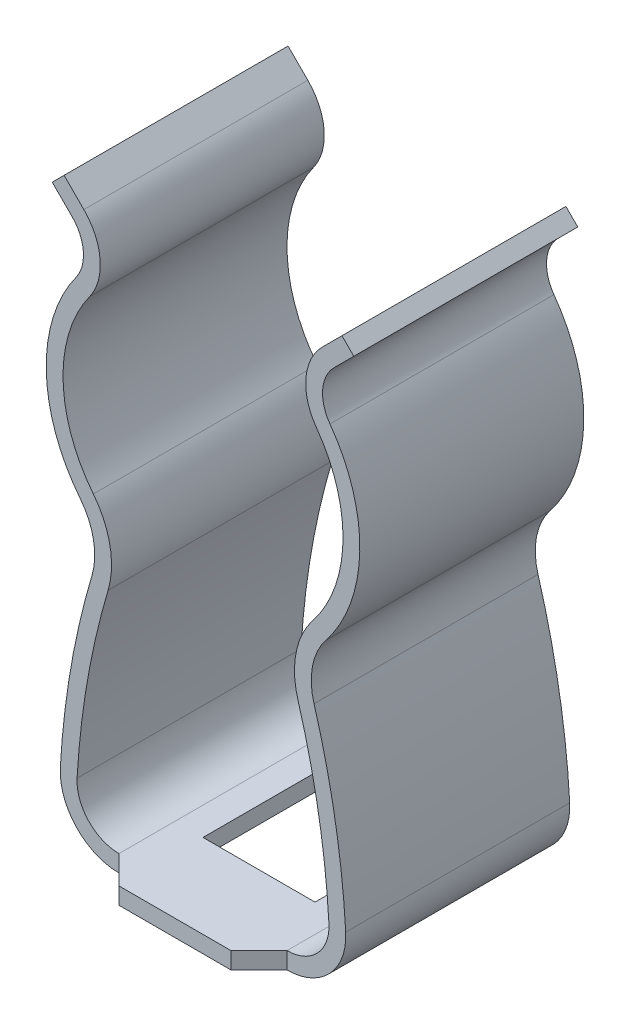
from build123d import *

# Parameters (mm, degrees)
EXTRUDE_1_DEPTH     = 2
EXTRUDE_1_2_DEPTH   = 0.3
CUT_EXTRUDE_1_REACH = 12.3
SKETCH_3_W          = 2
SKETCH_3_H          = 2


with BuildPart() as part:
    # Эскиз1 → Extrude 1 (new body, symmetric)
    with BuildSketch(Plane.XY):
        with BuildLine():
            Line((-2.480882446, 10), (-2.127329056, 9.646446609))
            ThreePointArc((-2.127329056, 9.646446609), (-1.837573649, 9.0184965), (-2.024597026, 8.352687375))
            ThreePointArc((-2.024597026, 8.352687375), (-2.499401746, 6.831367016), (-1.958507519, 5.332271091))
            ThreePointArc((-1.958507519, 5.332271091), (-1.661010167, 4.685383513), (-1.695318297, 3.974193548))
            ThreePointArc((-1.695318297, 3.974193548), (-2.06411065, 2.399336209), (-2.248797541, 0.79245283))
            ThreePointArc((-2.248797541, 0.79245283), (-2.045132838, 0.234897885), (-1.5, 0))
            Line((-1.5, 0), (0, 0))
            Line((0, 0), (0, -0.3))
            Line((0, -0.3), (-1.5, -0.3))
            ThreePointArc((-1.5, -0.3), (-2.263185974, 0.028857039), (-2.548316557, 0.809433962))
            ThreePointArc((-2.548316557, 0.809433962), (-2.359672091, 2.450750556), (-1.982977044, 4.059354839))
            ThreePointArc((-1.982977044, 4.059354839), (-1.95553054, 4.62830681), (-2.193528422, 5.145816873))
            ThreePointArc((-2.193528422, 5.145816873), (-2.799329956, 6.824804309), (-2.26754867, 8.528683111))
            ThreePointArc((-2.26754867, 8.528683111), (-2.136632306, 8.994749499), (-2.33946109, 9.434314575))
            Line((-2.33946109, 9.434314575), (-2.693014481, 9.787867966))
            Line((-2.693014481, 9.787867966), (-2.480882446, 10))
        make_face()
    extrude_1 = extrude(amount=EXTRUDE_1_DEPTH, both=True)

    # Зеркальное отражение1: Extrude 1 across plane
    add(extrude_1.mirror(Plane(origin=(0, 0, 0), x_dir=(0, 0, 1), z_dir=(1, 0, 0))))

    # Эскиз2 → Extrude 1 2 (add)
    with BuildSketch(Plane.XZ.offset(0.3)):
        Polygon((-1.5, 2), (-1, 2.5), (1, 2.5), (1.5, 2), align=None)
        Polygon((-1.5, -2), (-1, -2.5), (1, -2.5), (1.5, -2), align=None)
    extrude(amount=-EXTRUDE_1_2_DEPTH)

    # Эскиз3 → Вырез-Вытянуть1 (cut, up to next)
    with BuildSketch(Plane.XZ.offset(0.3), mode=Mode.PRIVATE) as cut_extrude_1_sk1:
        Rectangle(SKETCH_3_W, SKETCH_3_H)
    cut_extrude_1_tool1 = extrude(cut_extrude_1_sk1.sketch, amount=-CUT_EXTRUDE_1_REACH, mode=Mode.PRIVATE) & part.part
    add(cut_extrude_1_tool1.solids().sort_by_distance((0, -0.3, 0))[0], mode=Mode.SUBTRACT)


solid = part.part
